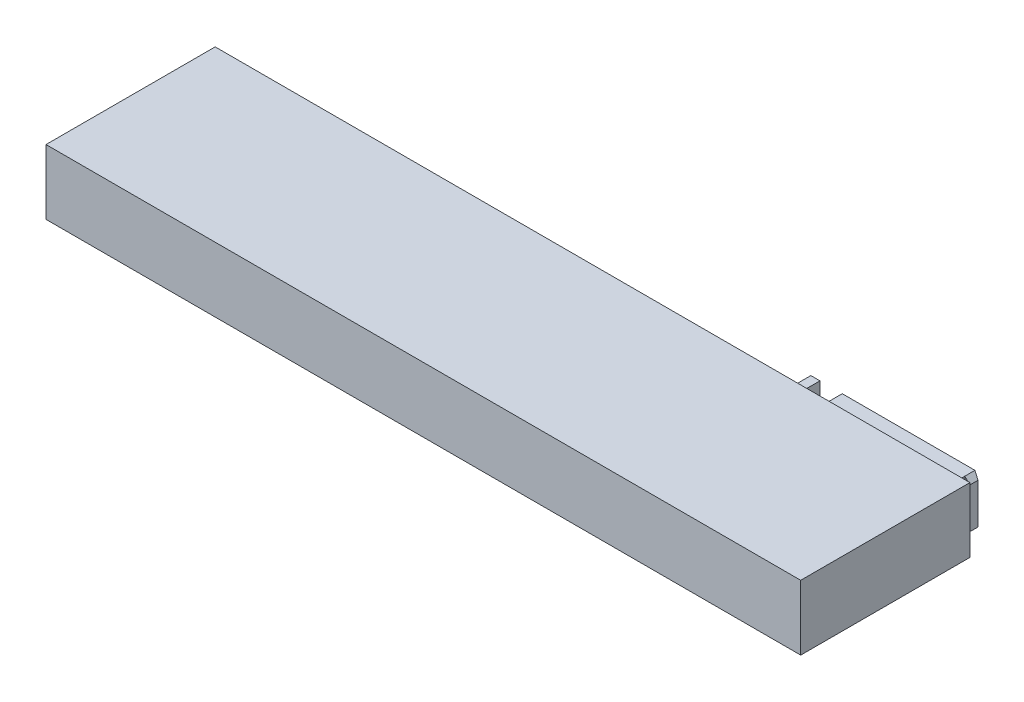
from build123d import *

# Parameters (mm, degrees)
SKETCH1_W             = 74.5
SKETCH1_H             = 16.7
BOSS_EXTRUDE1_DEPTH   = 6.4
SKETCH2_W             = 13.1
SKETCH2_H             = 5
SKETCH2_W_2           = 0.9
BOSS_EXTRUDE2_DEPTH   = 2
SKETCH3_R             = 1.05
CUT_EXTRUDE1_DEPTH    = 15
SKETCH4_W             = 1
SKETCH4_H             = 5
BOSS_EXTRUDE3_DEPTH   = 0.5
SKETCH5_W             = 1
SKETCH5_H             = 5
BOSS_EXTRUDE4_DEPTH   = 0.5
CHAMFER2_SIZE         = 0.5
CHAMFER2_SIZE2        = 0.2
CHAMFER2_PART_2_SIZE  = 0.5
CHAMFER2_PART_2_SIZE2 = 0.2
CHAMFER1_SIZE         = 0.5
SKETCH6_W             = 5
SKETCH6_H             = 4
BOSS_EXTRUDE5_DEPTH   = 0.3
SKETCH7_R             = 1.25
BOSS_EXTRUDE6_DEPTH   = 0.7


with BuildPart() as part:
    # Sketch1 → Boss-Extrude1 (new body)
    with BuildSketch(Plane(origin=(0, 0, 0), x_dir=(1, 0, 0), z_dir=(0, 1, 0))):
        with Locations((-37.25, 8.35)):
            Rectangle(SKETCH1_W, SKETCH1_H)
    extrude(amount=BOSS_EXTRUDE1_DEPTH)

    # Sketch2 → Boss-Extrude2 (add)
    with BuildSketch(Plane(origin=(0, 0, -16.7), x_dir=(-1, 0, 0), z_dir=(0, 0, -1))):
        with Locations((8.05, 3.2)):
            Rectangle(SKETCH2_W, SKETCH2_H)
        with Locations((17.25, 3.2)):
            Rectangle(SKETCH2_W_2, SKETCH2_H)
    extrude(amount=BOSS_EXTRUDE2_DEPTH)

    # Sketch3 → Cut-Extrude1 (cut)
    with BuildSketch(Plane(origin=(0, 0, -18.7), x_dir=(-1, 0, 0), z_dir=(0, 0, -1))):
        with Locations((5.1, 4.45)):
            Circle(SKETCH3_R)
        with Locations((7.6, 4.45)):
            Circle(SKETCH3_R)
        with Locations((10.1, 4.45)):
            Circle(SKETCH3_R)
        with Locations((12.6, 4.45)):
            Circle(SKETCH3_R)
        with Locations((12.6, 1.95)):
            Circle(SKETCH3_R)
        with Locations((10.1, 1.95)):
            Circle(SKETCH3_R)
        with Locations((7.6, 1.95)):
            Circle(SKETCH3_R)
        with Locations((5.1, 1.95)):
            Circle(SKETCH3_R)
    extrude(amount=-CUT_EXTRUDE1_DEPTH, mode=Mode.SUBTRACT)

    # Sketch4 → Boss-Extrude3 (add)
    with BuildSketch(Plane(origin=(-1.5, 0, 0), x_dir=(0, 0, -1), z_dir=(1, 0, 0))):
        with Locations((18.2, 3.2)):
            Rectangle(SKETCH4_W, SKETCH4_H)
    extrude(amount=BOSS_EXTRUDE3_DEPTH)

    # Sketch5 → Boss-Extrude4 (add)
    with BuildSketch(Plane.ZY.offset(17.7)):
        with Locations((-18.2, 3.2)):
            Rectangle(SKETCH5_W, SKETCH5_H)
    extrude(amount=BOSS_EXTRUDE4_DEPTH)

    # Chamfer2
    chamfer2_edges = [part.edges().sort_by_distance(p)[0] for p in [
        (-1, 3.2, -18.7),
    ]]
    chamfer2_side = [part.faces().sort_by_distance(p)[0] for p in [
        (-7.077898805, 3.2, -18.7),
    ]]
    chamfer(chamfer2_edges, length=CHAMFER2_SIZE, length2=CHAMFER2_SIZE2, reference=chamfer2_side[0])

    # Chamfer2 part 2
    chamfer2_part_2_edges = [part.edges().sort_by_distance(p)[0] for p in [
        (-18.2, 3.2, -18.7),
    ]]
    chamfer2_part_2_side = [part.faces().sort_by_distance(p)[0] for p in [
        (-17.5, 3.2, -18.7),
    ]]
    chamfer(chamfer2_part_2_edges, length=CHAMFER2_PART_2_SIZE, length2=CHAMFER2_PART_2_SIZE2, reference=chamfer2_part_2_side[0])

    # Chamfer1
    chamfer1_edges = [part.edges().sort_by_distance(p)[0] for p in [
        (-18.2, 0.7, -18.1),
        (-18.2, 5.7, -18.1),
        (-1, 5.7, -18.1),
        (-1, 0.7, -18.1),
    ]]
    chamfer(chamfer1_edges, length=CHAMFER1_SIZE)

    # Sketch6 → Boss-Extrude5 (add)
    with BuildSketch(Plane(origin=(0, 0, -16.7), x_dir=(-1, 0, 0), z_dir=(0, 0, -1))):
        with Locations((24, 3.2)):
            Rectangle(SKETCH6_W, SKETCH6_H)
    extrude(amount=BOSS_EXTRUDE5_DEPTH)

    # Sketch7 → Boss-Extrude6 (add)
    with BuildSketch(Plane(origin=(0, 0, -17), x_dir=(-1, 0, 0), z_dir=(0, 0, -1))):
        with Locations((24, 3.2)):
            Circle(SKETCH7_R)
    extrude(amount=BOSS_EXTRUDE6_DEPTH)


solid = part.part
